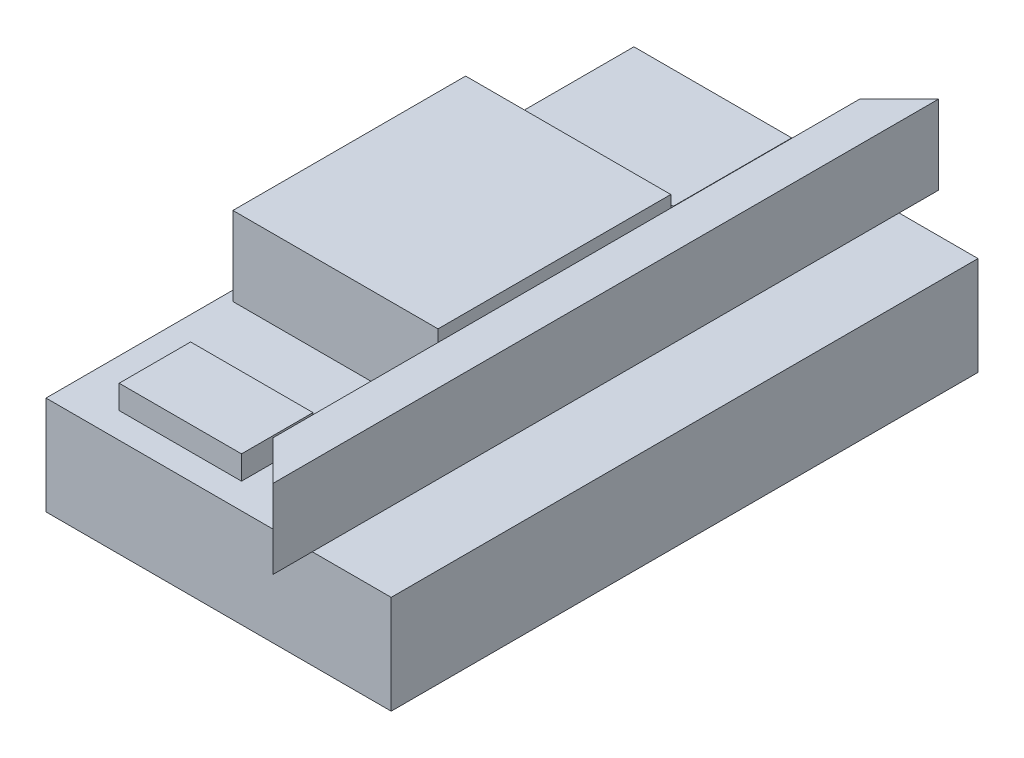
from build123d import *

# Parameters (mm, degrees)
SKETCH1_W           = 222.25
SKETCH1_H           = 63.5
BOSS_EXTRUDE1_DEPTH = 377.825
SKETCH2_W           = 25.4
SKETCH2_H           = 428.625
BOSS_EXTRUDE2_DEPTH = 50.8
SKETCH3_W           = 132.08
SKETCH3_H           = 149.86
BOSS_EXTRUDE3_DEPTH = 50.8
SKETCH4_W           = 101.6
SKETCH4_H           = 76.2
BOSS_EXTRUDE4_DEPTH = 25.4
SKETCH5_W           = 78.778649954
SKETCH5_H           = 46.015700821
BOSS_EXTRUDE5_DEPTH = 15.24
CUT_EXTRUDE1_DEPTH  = 127


with BuildPart() as part:
    # Sketch1 → Boss-Extrude1 (new body)
    with BuildSketch(Plane.XY):
        with Locations((111.125, 31.75)):
            Rectangle(SKETCH1_W, SKETCH1_H)
    extrude(amount=BOSS_EXTRUDE1_DEPTH)

    # Sketch2 → Boss-Extrude2 (add)
    with BuildSketch(Plane(origin=(0, 63.5, 0), x_dir=(1, 0, 0), z_dir=(0, 1, 0))):
        with Locations((158.75, -188.9125)):
            Rectangle(SKETCH2_W, SKETCH2_H)
    extrude(amount=BOSS_EXTRUDE2_DEPTH)

    # Sketch3 → Boss-Extrude3 (add)
    with BuildSketch(Plane(origin=(0, 63.5, 0), x_dir=(1, 0, 0), z_dir=(0, 1, 0))):
        with Locations((72.39, -188.9125)):
            Rectangle(SKETCH3_W, SKETCH3_H)
    extrude(amount=BOSS_EXTRUDE3_DEPTH)

    # Sketch4 → Boss-Extrude4 (add)
    with BuildSketch(Plane(origin=(0, 63.5, 0), x_dir=(1, 0, 0), z_dir=(0, 1, 0))):
        with Locations((69.606671705, -56.197197529)):
            Rectangle(SKETCH4_W, SKETCH4_H)
    extrude(amount=BOSS_EXTRUDE4_DEPTH)

    # Sketch5 → Boss-Extrude5 (add)
    with BuildSketch(Plane(origin=(0, 63.5, 0), x_dir=(1, 0, 0), z_dir=(0, 1, 0))):
        with Locations((69.91393095, -338.241458835)):
            Rectangle(SKETCH5_W, SKETCH5_H)
    extrude(amount=BOSS_EXTRUDE5_DEPTH)

    # Sketch8 → Cut-Extrude1 (cut)
    with BuildSketch(Plane(origin=(0, 114.3, 0), x_dir=(1, 0, 0), z_dir=(0, 1, 0))):
        Polygon((171.45, 25.4), (146.05, 0), (146.05, 25.4), align=None)
        Polygon((171.45, -403.225), (146.05, -377.825), (146.05, -403.225), align=None)
    extrude(amount=-CUT_EXTRUDE1_DEPTH, mode=Mode.SUBTRACT)


solid = part.part
